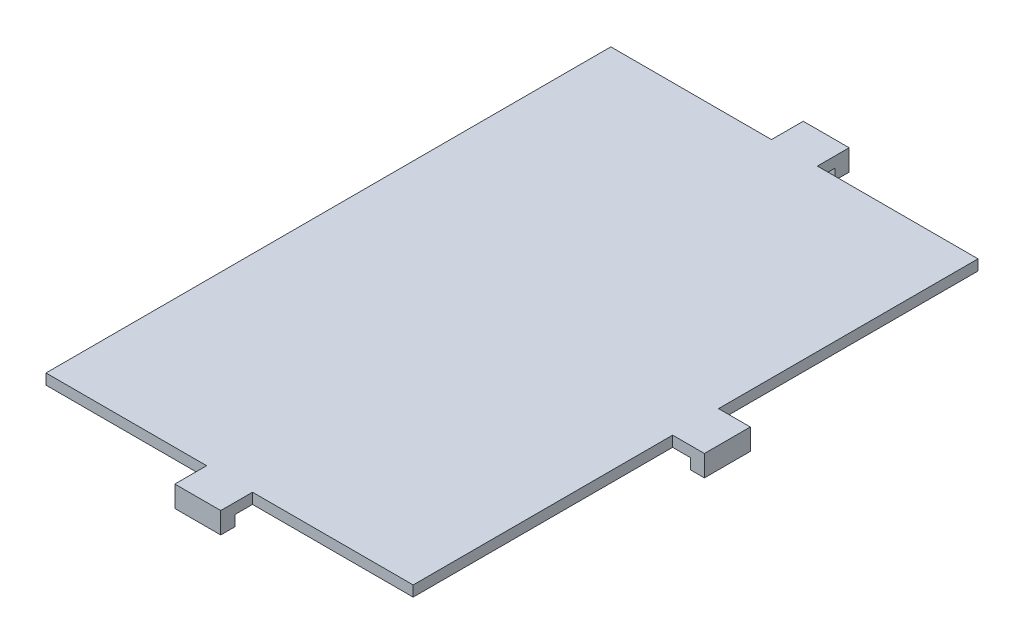
from build123d import *

# Parameters (mm, degrees)
BOSS_EXTRUDE1_DEPTH = 1.5
SKETCH2_W           = 7
SKETCH2_H           = 2
SKETCH2_W_2         = 2
SKETCH2_H_2         = 7
BOSS_EXTRUDE2_DEPTH = 3
SKETCH3_W           = 23
SKETCH3_H           = 0.5
CUT_EXTRUDE1_DEPTH  = 10
SKETCH4_W           = 23
SKETCH4_H           = 0.5
CUT_EXTRUDE2_DEPTH  = 10
SKETCH5_W           = 0.25
SKETCH5_H           = 4.5
SKETCH5_W_2         = 4
SKETCH5_H_2         = 0.25
CUT_EXTRUDE3_DEPTH  = 10
SKETCH6_W           = 0.5
SKETCH6_H           = 80
SKETCH6_H_2         = 36.75
CUT_EXTRUDE4_DEPTH  = 10


with BuildPart() as part:
    # Sketch1 → Boss-Extrude1 (new body)
    with BuildSketch(Plane(origin=(0, 0, 0), x_dir=(1, 0, 0), z_dir=(0, 1, 0))):
        Polygon((30, 81), (53, 81), (53, 44), (55, 44), (55, 37), (53, 37), (53, 0), (30, 0), (30, -2), (23, -2), (23, 0), (0, 0), (0, 81), (23, 81), (23, 83), (30, 83), align=None)
    extrude(amount=BOSS_EXTRUDE1_DEPTH)

    # Sketch2 → Boss-Extrude2 (add)
    with BuildSketch(Plane(origin=(0, 1.5, 0), x_dir=(1, 0, 0), z_dir=(0, 1, 0))):
        with Locations((26.5, 84)):
            Rectangle(SKETCH2_W, SKETCH2_H)
        with Locations((56, 40.5)):
            Rectangle(SKETCH2_W_2, SKETCH2_H_2)
        with Locations((26.5, -3)):
            Rectangle(SKETCH2_W, SKETCH2_H)
    extrude(amount=-BOSS_EXTRUDE2_DEPTH)

    # Sketch3 → Cut-Extrude1 (cut)
    with BuildSketch(Plane(origin=(0, 1.5, 0), x_dir=(1, 0, 0), z_dir=(0, 1, 0))):
        with Locations((11.5, 80.75)):
            Rectangle(SKETCH3_W, SKETCH3_H)
        with Locations((41.5, 80.75)):
            Rectangle(SKETCH3_W, SKETCH3_H)
    extrude(amount=-CUT_EXTRUDE1_DEPTH, mode=Mode.SUBTRACT)

    # Sketch4 → Cut-Extrude2 (cut)
    with BuildSketch(Plane(origin=(0, 1.5, 0), x_dir=(1, 0, 0), z_dir=(0, 1, 0))):
        with Locations((11.5, 0.25)):
            Rectangle(SKETCH4_W, SKETCH4_H)
        with Locations((41.5, 0.25)):
            Rectangle(SKETCH4_W, SKETCH4_H)
    extrude(amount=-CUT_EXTRUDE2_DEPTH, mode=Mode.SUBTRACT)

    # Sketch5 → Cut-Extrude3 (cut)
    with BuildSketch(Plane(origin=(0, 1.5, 0), x_dir=(1, 0, 0), z_dir=(0, 1, 0))):
        with Locations((23.125, 82.75)):
            Rectangle(SKETCH5_W, SKETCH5_H)
        with Locations((29.875, 82.75)):
            Rectangle(SKETCH5_W, SKETCH5_H)
        with Locations((55, 43.875)):
            Rectangle(SKETCH5_W_2, SKETCH5_H_2)
        with Locations((55, 37.125)):
            Rectangle(SKETCH5_W_2, SKETCH5_H_2)
        with Locations((23.125, -1.75)):
            Rectangle(SKETCH5_W, SKETCH5_H)
        with Locations((29.875, -1.75)):
            Rectangle(SKETCH5_W, SKETCH5_H)
    extrude(amount=-CUT_EXTRUDE3_DEPTH, mode=Mode.SUBTRACT)

    # Sketch6 → Cut-Extrude4 (cut)
    with BuildSketch(Plane(origin=(0, 1.5, 0), x_dir=(1, 0, 0), z_dir=(0, 1, 0))):
        with Locations((0.25, 40.5)):
            Rectangle(SKETCH6_W, SKETCH6_H)
        with Locations((52.75, 18.875)):
            Rectangle(SKETCH6_W, SKETCH6_H_2)
        with Locations((52.75, 62.125)):
            Rectangle(SKETCH6_W, SKETCH6_H_2)
    extrude(amount=-CUT_EXTRUDE4_DEPTH, mode=Mode.SUBTRACT)


solid = part.part
